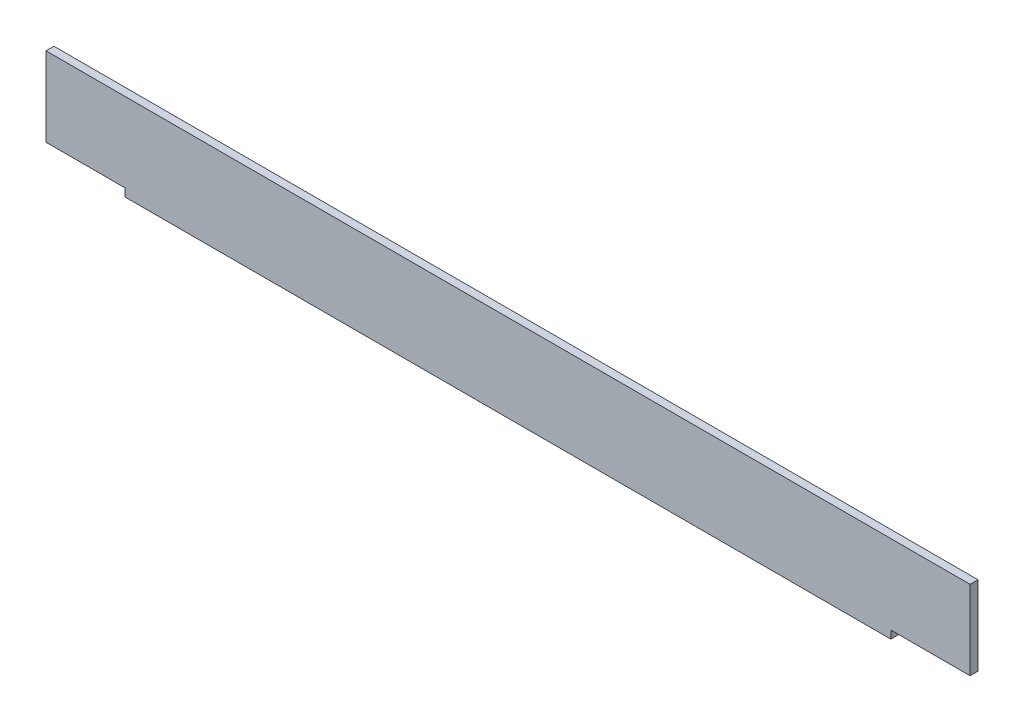
from build123d import *

# Parameters (mm, degrees)
EXTRUDE_1_DEPTH     = 350
SKETCH_2_W          = 30
SKETCH_2_H          = 33
CUT_EXTRUDE_1_DEPTH = 3


with BuildPart() as part:
    # Эскиз1 → Вытянуть-Тонкостенный1 (new body)
    with BuildSketch(Plane(origin=(0, 0, 0), x_dir=(0, 0, -1), z_dir=(1, 0, 0))):
        Polygon((0, 33), (0, 0), (33, 0), (33, 3), (3, 3), (3, 33), align=None)
    extrude(amount=EXTRUDE_1_DEPTH)

    # Эскиз2 → Вырез-Вытянуть1 (cut)
    with BuildSketch(Plane.XZ):
        with Locations((15, -16.5)):
            Rectangle(SKETCH_2_W, SKETCH_2_H)
        with Locations((335, -16.5)):
            Rectangle(SKETCH_2_W, SKETCH_2_H)
    extrude(amount=-CUT_EXTRUDE_1_DEPTH, mode=Mode.SUBTRACT)


solid = part.part
